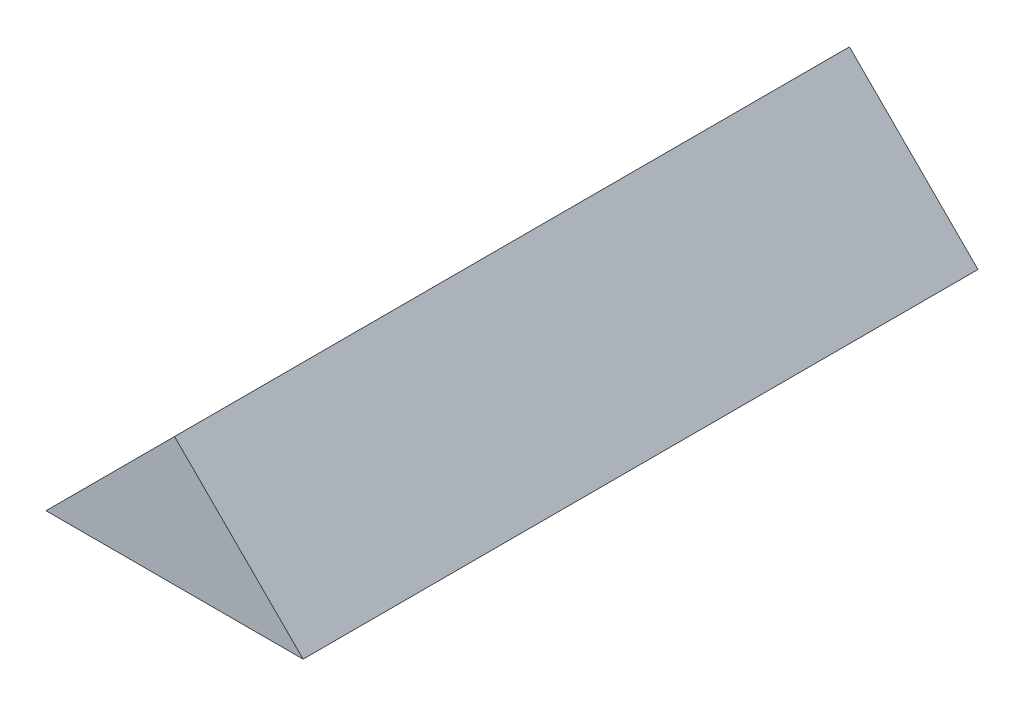
from build123d import *

# Parameters (mm, degrees)
EXTRUSION1_DEPTH = 105


with BuildPart() as part:
    # Esquisse1 → Extrusion1 (new body)
    with BuildSketch(Plane.XY):
        Polygon((0, 0), (40, 0), (20.000000004, 20), align=None)
    extrude(amount=-EXTRUSION1_DEPTH)


solid = part.part
